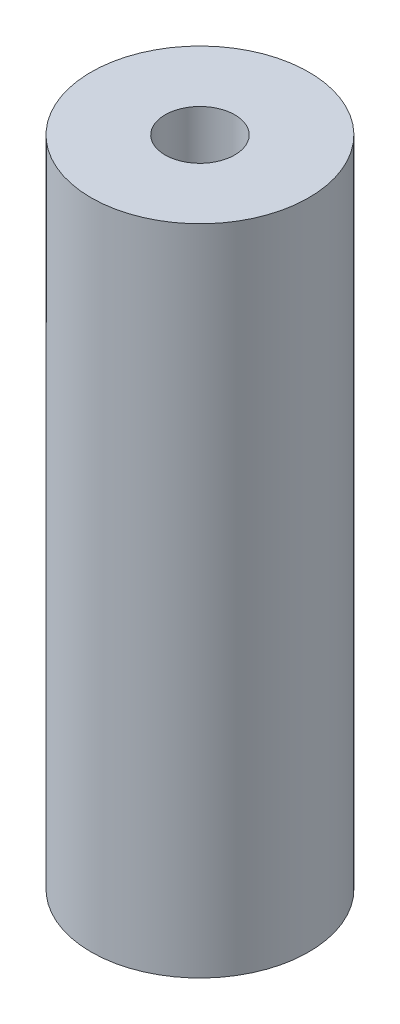
from build123d import *

# Parameters (mm, degrees)
SKETCH1_R           = 12.7
SKETCH1_R_2         = 4.064
BOSS_EXTRUDE1_DEPTH = 76.2


with BuildPart() as part:
    # Sketch1 → Boss-Extrude1 (new body)
    with BuildSketch(Plane(origin=(0, 0, 0), x_dir=(1, 0, 0), z_dir=(0, 1, 0))):
        Circle(SKETCH1_R)
        Circle(SKETCH1_R_2, mode=Mode.SUBTRACT)
    extrude(amount=BOSS_EXTRUDE1_DEPTH)


solid = part.part
